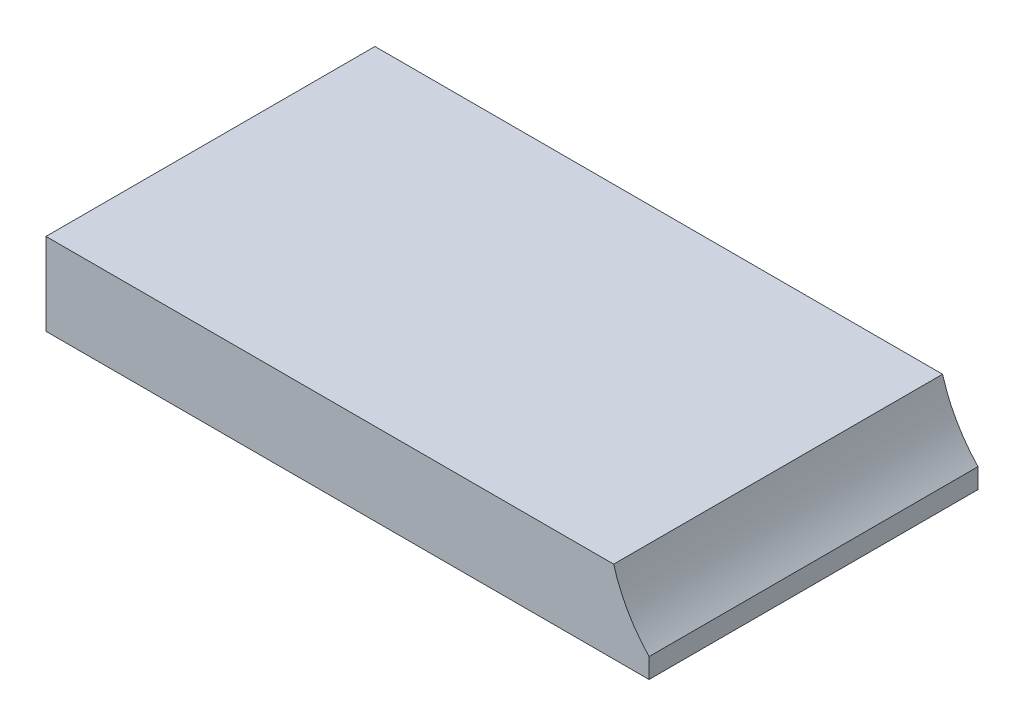
from build123d import *

# Parameters (mm, degrees)
SKETCH_1_W          = 22
SKETCH_1_H          = 12
EXTRUDE_1_DEPTH     = 3
SKETCH_2_R          = 5.5
CUT_EXTRUDE_1_DEPTH = 13


with BuildPart() as part:
    # Эскиз1 → Бобышка-Вытянуть1 (new body)
    with BuildSketch(Plane(origin=(0, 0, 0), x_dir=(1, 0, 0), z_dir=(0, 1, 0))):
        with Locations((11, 6)):
            Rectangle(SKETCH_1_W, SKETCH_1_H)
    extrude(amount=EXTRUDE_1_DEPTH)

    # Эскиз2 → Вырез-Вытянуть1 (cut, through all)
    with BuildSketch(Plane.XY):
        with Locations((26, 4.5)):
            Circle(SKETCH_2_R)
    extrude(amount=-CUT_EXTRUDE_1_DEPTH, mode=Mode.SUBTRACT)


solid = part.part
